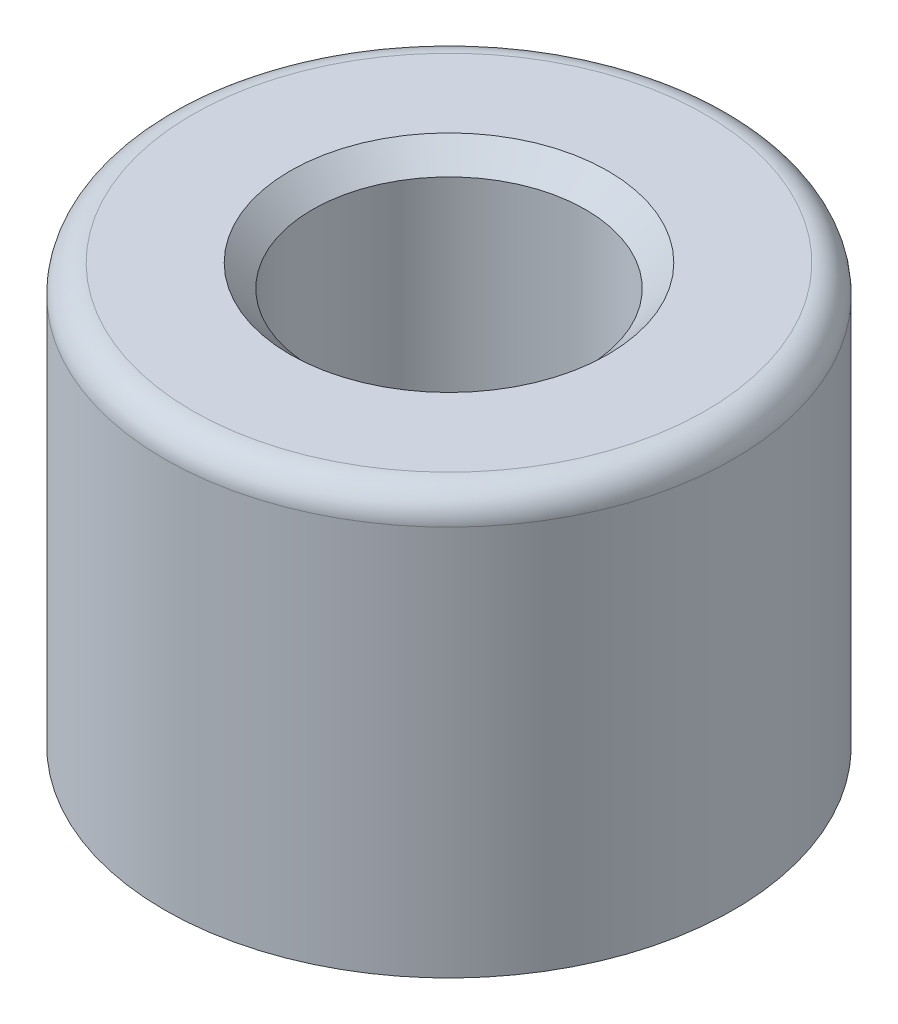
from build123d import *

# Parameters (mm, degrees)
SKETCH1_R                   = 6.477
BOSS_EXTRUDE1_DEPTH         = 9.525
FILLET1_R                   = 0.635
F_1_4_20_TAPPED_HOLE1_D     = 6.223
F_1_4_20_TAPPED_HOLE1_DEPTH = 9.525
F_1_4_20_TAPPED_HOLE1_TIP   = 1.869577816
CHAMFER1_SIZE               = 0.508


with BuildPart() as part:
    # Sketch1 → Boss-Extrude1 (new body)
    with BuildSketch(Plane(origin=(0, 0, 0), x_dir=(1, 0, 0), z_dir=(0, 1, 0))):
        Circle(SKETCH1_R)
    extrude(amount=BOSS_EXTRUDE1_DEPTH)

    # Fillet1
    fillet1_edges = [part.edges().sort_by_distance(p)[0] for p in [
        (-6.477, 9.525, 0),
    ]]
    fillet(fillet1_edges, radius=FILLET1_R)

    # 1/4-20 Tapped Hole1
    with Locations(Plane(origin=(0, 9.525, 0), x_dir=(1, 0, 0), z_dir=(0, 1, 0))):
        with Locations((0, 0)):
            Hole(F_1_4_20_TAPPED_HOLE1_D / 2, depth=F_1_4_20_TAPPED_HOLE1_DEPTH)
            with Locations((0, 0, -(F_1_4_20_TAPPED_HOLE1_DEPTH + F_1_4_20_TAPPED_HOLE1_TIP / 2))):  # 118° drill point
                Cone(0, F_1_4_20_TAPPED_HOLE1_D / 2, F_1_4_20_TAPPED_HOLE1_TIP, mode=Mode.SUBTRACT)

    # Chamfer1
    chamfer1_edges = [part.edges().sort_by_distance(p)[0] for p in [
        (3.1115, 9.525, 0),
    ]]
    chamfer(chamfer1_edges, length=CHAMFER1_SIZE)


solid = part.part
